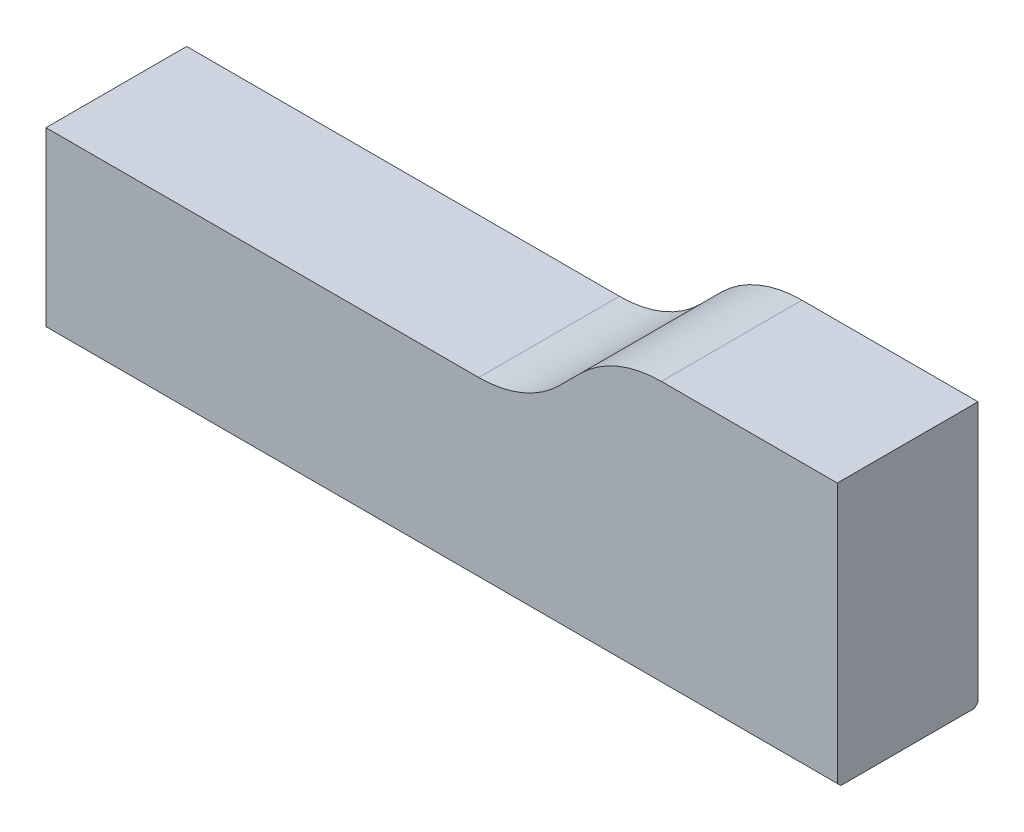
from build123d import *

# Parameters (mm, degrees)
BOSS_EXTRUDE1_DEPTH   = 8
FILLET1_R             = 6.5
CHAMFER1_SIZE         = 0.2
M3_TAPPED_HOLE1_D     = 2.5
M3_TAPPED_HOLE1_DEPTH = 6
M3_TAPPED_HOLE1_TIP   = 0.751075774


with BuildPart() as part:
    # Sketch1 → Boss-Extrude1 (new body)
    with BuildSketch(Plane.XY):
        Polygon((-1.56097561, 4.365853659), (3.43902439, 9.365853659), (16.13902439, 9.365853659), (16.13902439, -5.634146341), (-28.86097561, -5.634146341), (-28.86097561, 4.365853659), align=None)
    extrude(amount=BOSS_EXTRUDE1_DEPTH)

    # Fillet1
    fillet1_edges = [part.edges().sort_by_distance(p)[0] for p in [
        (-1.56097561, 4.365853659, 4),
        (3.43902439, 9.365853659, 4),
    ]]
    fillet(fillet1_edges, radius=FILLET1_R)

    # Chamfer1
    chamfer1_edges = [part.edges().sort_by_distance(p)[0] for p in [
        (-6.36097561, -5.634146341, 8),
        (-6.36097561, -5.634146341, 0),
    ]]
    chamfer(chamfer1_edges, length=CHAMFER1_SIZE)

    # M3 Tapped Hole1
    with Locations(Plane(origin=(0, -5.634146341, 0), x_dir=(-1, 0, 0), z_dir=(0, -1, 0))):
        with Locations((21.36097561, -4), (-8.63902439, -4)):
            Hole(M3_TAPPED_HOLE1_D / 2, depth=M3_TAPPED_HOLE1_DEPTH)
            with Locations((0, 0, -(M3_TAPPED_HOLE1_DEPTH + M3_TAPPED_HOLE1_TIP / 2))):  # 118° drill point
                Cone(0, M3_TAPPED_HOLE1_D / 2, M3_TAPPED_HOLE1_TIP, mode=Mode.SUBTRACT)


solid = part.part
